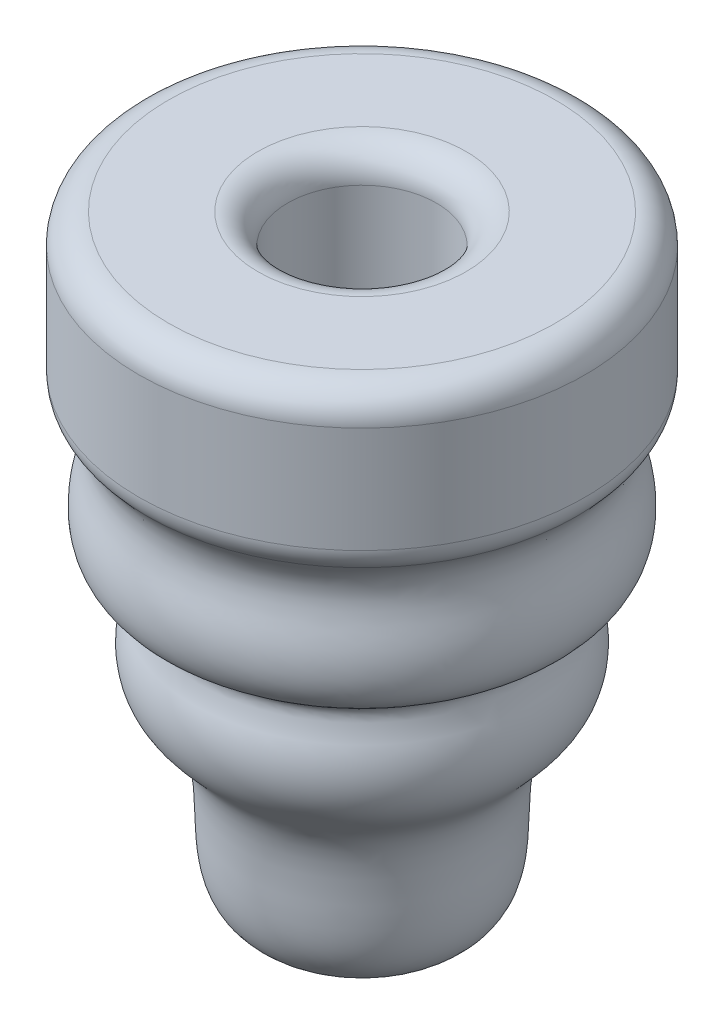
from build123d import *


with BuildPart() as part:
    # Sketch2 → Revolve1 (revolve)
    with BuildSketch(Plane(origin=(0, 0, 0), x_dir=(0, 0, -1), z_dir=(1, 0, 0)), mode=Mode.PRIVATE) as revolve1_sk:
        with BuildLine():
            Line((0, 0), (0, 18.671764032))
            Line((0, 18.671764032), (6.35, 18.671764032))
            Line((6.35, 18.671764032), (6.35, 28.831764032))
            ThreePointArc((6.35, 28.831764032), (7.093948776, 30.627815256), (8.89, 31.371764032))
            Line((8.89, 31.371764032), (16.51, 31.371764032))
            ThreePointArc((16.51, 31.371764032), (18.306051224, 30.627815256), (19.05, 28.831764032))
            Line((19.05, 28.831764032), (19.05, 19.783586538))
            ThreePointArc((19.05, 19.783586538), (18.861627544, 18.823665763), (18.324450478, 18.006125016))
            add(Edge.make_bspline(
                [(18.324450478, 18.006125016), (16.554325637, 16.199163894), (16.848701293, 13.963887666), (17.943123957, 10.164070416), (17.706795968, 6.209672719), (13.115810786, 4.785092209), (15.25580492, 0.707996921), (14.719217473, -3.715486091), (6.581664428, -9.88711356), (14.324406115, -22.121467329), (0, -21.074843533)],
                knots=[0.013383664, 0.013383664, 0.013383664, 0.013383664, 0.124755143, 0.165582908, 0.26861116, 0.337747288, 0.396161031, 0.508806563, 0.603969639, 1, 1, 1, 1], degree=3))
            Line((0, -21.074843533), (0, 0))
        make_face()
    revolve(revolve1_sk.sketch.rotate(Axis((0, 80.004180985, 0), (0, -1, 0)), 180), axis=Axis((0, 80.004180985, 0), (0, -1, 0)))  # turned: the seam where the file's is


solid = part.part
